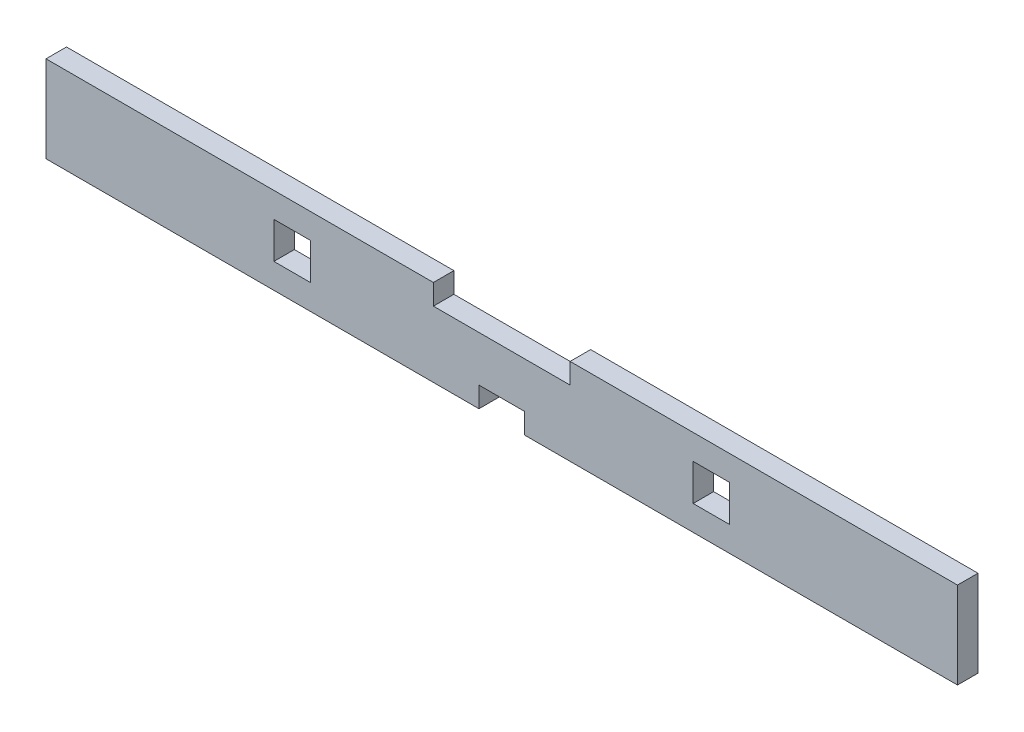
from build123d import *

# Parameters (mm, degrees)
SKETCH1_W           = 254
SKETCH1_H           = 50.8
BOSS_EXTRUDE1_DEPTH = 5.715
SKETCH2_W           = 10.16
SKETCH2_H           = 10.16
SKETCH2_W_2         = 12.7
SKETCH2_H_2         = 5.715
SKETCH2_W_3         = 38.1
CUT_EXTRUDE1_DEPTH  = 6.715
CUT_EXTRUDE2_DEPTH  = 6.715


with BuildPart() as part:
    # Sketch1 → Boss-Extrude1 (new body)
    with BuildSketch(Plane.XY):
        Rectangle(SKETCH1_W, SKETCH1_H)
    extrude(amount=BOSS_EXTRUDE1_DEPTH)

    # Sketch2 → Cut-Extrude1 (cut, through all)
    with BuildSketch(Plane.XY.offset(5.715)):
        with Locations((-58.42, 0)):
            Rectangle(SKETCH2_W, SKETCH2_H)
        with Locations((58.42, 0)):
            Rectangle(SKETCH2_W, SKETCH2_H)
        with Locations((0, -9.2075)):
            Rectangle(SKETCH2_W_2, SKETCH2_H_2)
        with Locations((0, 9.2075)):
            Rectangle(SKETCH2_W_3, SKETCH2_H_2)
    extrude(amount=-CUT_EXTRUDE1_DEPTH, mode=Mode.SUBTRACT)

    # Sketch3 → Cut-Extrude2 (cut, through all)
    with BuildSketch(Plane.XY.offset(5.715)):
        Polygon((-127, 25.4), (-127, 12.065), (-19.05, 12.065), (19.05, 12.065), (127, 12.065), (127, 25.4), align=None)
        Polygon((-6.35, -12.065), (-127, -12.065), (-127, -25.4), (127, -25.4), (127, -12.065), (6.35, -12.065), align=None)
    extrude(amount=-CUT_EXTRUDE2_DEPTH, mode=Mode.SUBTRACT)


solid = part.part
